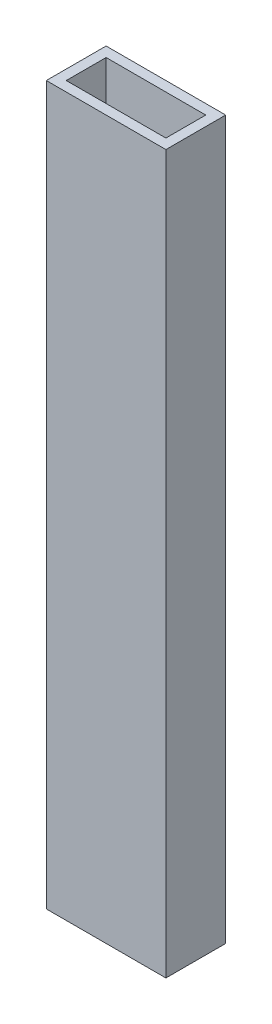
from build123d import *

# Parameters (mm, degrees)
SKETCH1_W           = 38.1
SKETCH1_H           = 19.05
SKETCH1_W_2         = 31.75
SKETCH1_H_2         = 12.7
BOSS_EXTRUDE1_DEPTH = 228.6


with BuildPart() as part:
    # Sketch1 → Boss-Extrude1 (new body)
    with BuildSketch(Plane(origin=(0, 0, 0), x_dir=(1, 0, 0), z_dir=(0, 1, 0))):
        with Locations((19.05, 9.525)):
            Rectangle(SKETCH1_W, SKETCH1_H)
        with Locations((19.05, 9.525)):
            Rectangle(SKETCH1_W_2, SKETCH1_H_2, mode=Mode.SUBTRACT)
    extrude(amount=BOSS_EXTRUDE1_DEPTH)


solid = part.part
